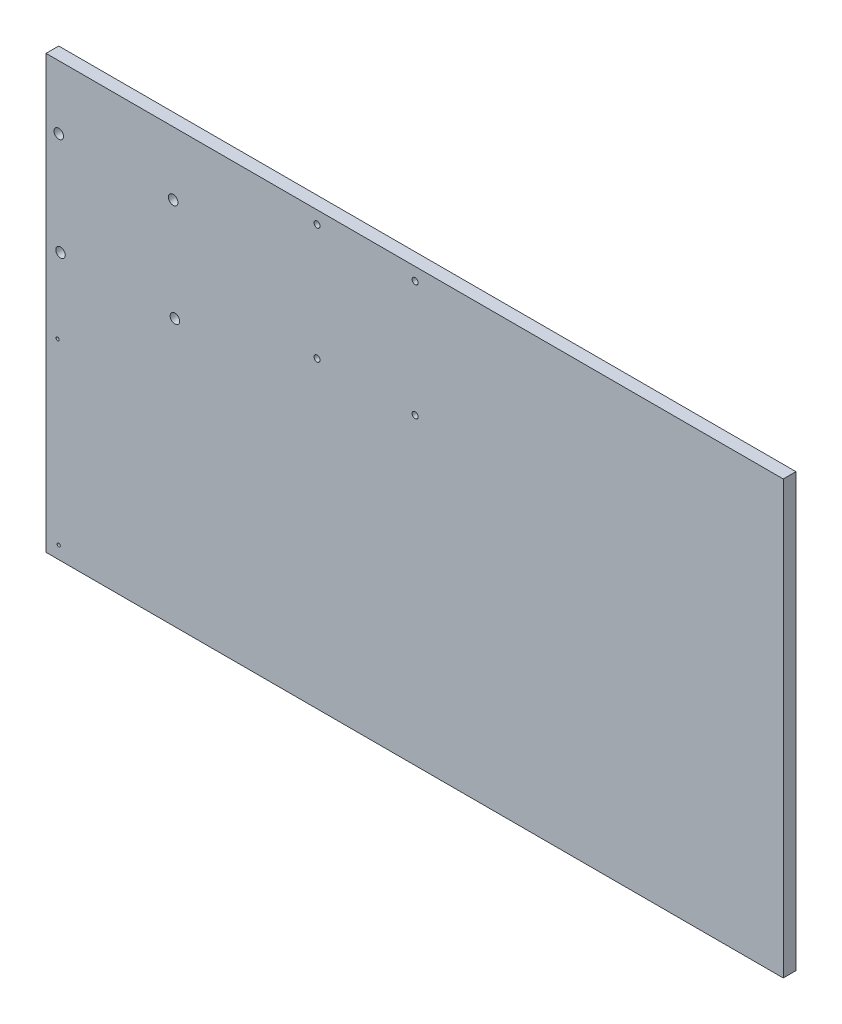
from build123d import *

# Parameters (mm, degrees)
SKETCH1_W           = 215.9
SKETCH1_H           = 215.9
BOSS_EXTRUDE1_DEPTH = 6.35
SKETCH2_R           = 0.79883
CUT_EXTRUDE1_DEPTH  = 7.35
SKETCH3_R           = 2.3749
CUT_EXTRUDE2_DEPTH  = 7.35
SKETCH4_R           = 1.4986
CUT_EXTRUDE4_DEPTH  = 7.35
SKETCH5_W           = 215.9
SKETCH5_H           = 6.35
BOSS_EXTRUDE2_DEPTH = 152.4


with BuildPart() as part:
    # Sketch1 → Boss-Extrude1 (new body)
    with BuildSketch(Plane(origin=(0, 0, 0), x_dir=(0, 1, 0), z_dir=(0, 0, 1))):
        with Locations((107.95, 107.95)):
            Rectangle(SKETCH1_W, SKETCH1_H)
    extrude(amount=BOSS_EXTRUDE1_DEPTH)

    # Sketch2 → Cut-Extrude1 (cut, through all)
    with BuildSketch(Plane.XY.offset(6.35)):
        with Locations((-209.55, 6.35)):
            Circle(SKETCH2_R)
        with Locations((-210.114382122, 95.24820849)):
            Circle(SKETCH2_R)
    extrude(amount=-CUT_EXTRUDE1_DEPTH, mode=Mode.SUBTRACT)

    # Sketch3 → Cut-Extrude2 (cut, through all)
    with BuildSketch(Plane.XY.offset(6.35)):
        with Locations((-209.55, 184.30334861)):
            Circle(SKETCH3_R)
        with Locations((-208.660508776, 133.34820849)):
            Circle(SKETCH3_R)
        with Locations((-152.400004812, 184.27989595)):
            Circle(SKETCH3_R)
        with Locations((-151.510508804, 133.349999963)):
            Circle(SKETCH3_R)
    extrude(amount=-CUT_EXTRUDE2_DEPTH, mode=Mode.SUBTRACT)

    # Sketch4 → Cut-Extrude4 (cut, through all)
    with BuildSketch(Plane.XY.offset(6.35)):
        with Locations((-80.512162715, 209.55)):
            Circle(SKETCH4_R)
        with Locations((-31.515562715, 209.55)):
            Circle(SKETCH4_R)
        with Locations((-80.512162715, 151.5618)):
            Circle(SKETCH4_R)
        with Locations((-31.515562715, 151.5618)):
            Circle(SKETCH4_R)
    extrude(amount=-CUT_EXTRUDE4_DEPTH, mode=Mode.SUBTRACT)

    # Sketch5 → Boss-Extrude2 (add)
    with BuildSketch(Plane.YZ):
        with Locations((107.95, 3.175)):
            Rectangle(SKETCH5_W, SKETCH5_H)
    extrude(amount=BOSS_EXTRUDE2_DEPTH)


solid = part.part
